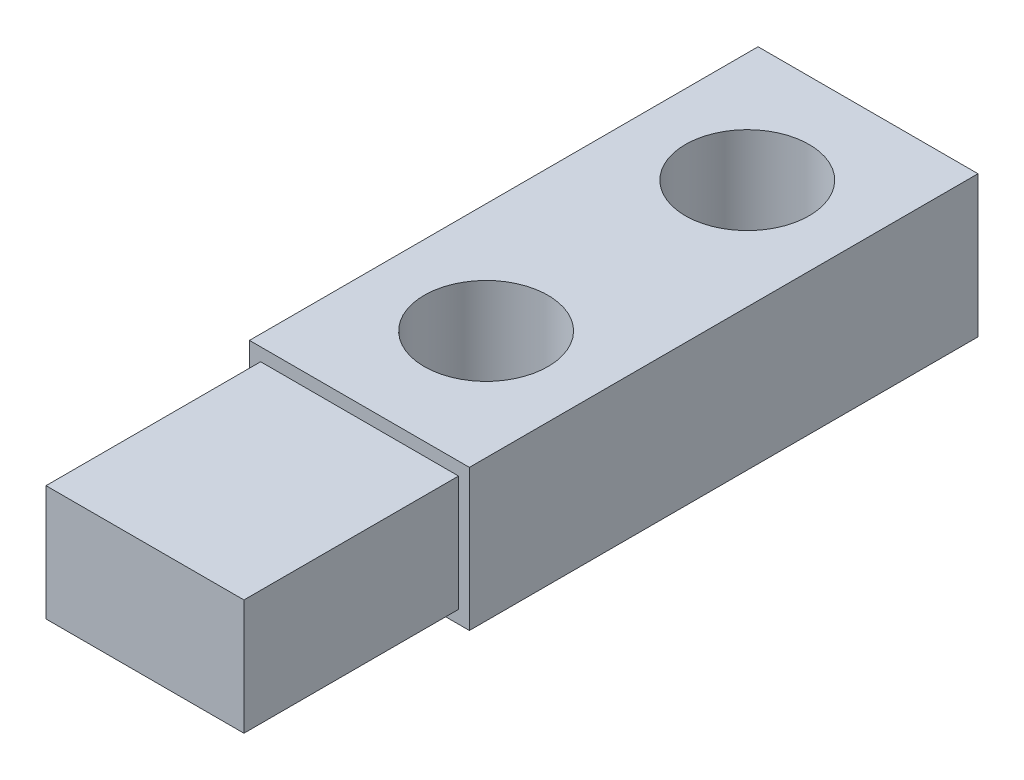
from build123d import *

# Parameters (mm, degrees)
SKETCH1_R           = 2.25
BOSS_EXTRUDE1_DEPTH = 5.14
BOSS_EXTRUDE2_START = 0.47
SKETCH1_4_W         = 7.2
SKETCH1_4_H         = 7.806654437
BOSS_EXTRUDE2_DEPTH = 4.2


with BuildPart() as part:
    # Sketch1 → Boss-Extrude1 (new body)
    with BuildSketch(Plane(origin=(0, 0, 0), x_dir=(1, 0, 0), z_dir=(0, 1, 0))):
        Polygon((3.794030202, 10.638672352), (-4.205969798, 10.638672352), (-4.205969798, -7.861327648), (-3.8, -7.861327648), (3.4, -7.861327648), (3.794030202, -7.861327648), align=None)
        with Locations((-0.2, -3.25974881)):
            Circle(SKETCH1_R, mode=Mode.SUBTRACT)
        with Locations((-0.2, 6.24025119)):
            Circle(SKETCH1_R, mode=Mode.SUBTRACT)
    extrude(amount=BOSS_EXTRUDE1_DEPTH)

    # Sketch1_4 → Boss-Extrude2 (add)
    with BuildSketch(Plane(origin=(0, 0, 0), x_dir=(1, 0, 0), z_dir=(0, 1, 0)).offset(BOSS_EXTRUDE2_START)):
        with Locations((-0.2, -11.764654867)):
            Rectangle(SKETCH1_4_W, SKETCH1_4_H)
    extrude(amount=BOSS_EXTRUDE2_DEPTH)


solid = part.part
